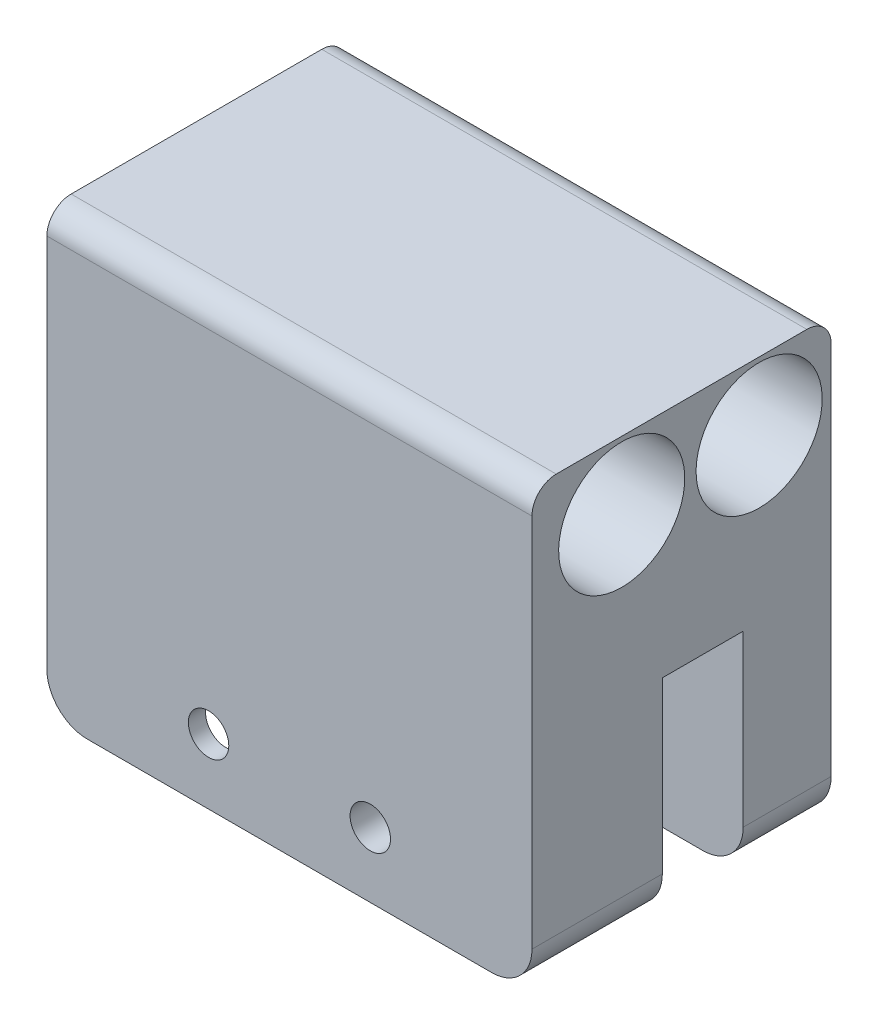
from build123d import *

# Parameters (mm, degrees)
RESSALTO_EXTRUS_O1_DEPTH = 40
ESBO_O4_R                = 7.8
CORTE_EXTRUS_O1_DEPTH    = 61
CORTE_EXTRUS_O2_DEPTH    = 3
FILETE2_R                = 3
CORTE_EXTRUS_O5_DEPTH    = 61
ESBO_O10_R               = 2.5
CORTE_EXTRUS_O6_DEPTH    = 38
ESBO_O11_R               = 4.25
CORTE_EXTRUS_O7_DEPTH    = 30
CORTE_EXTRUS_O8_DEPTH    = 30
ESBO_O13_W               = 2
ESBO_O13_H               = 5
RESSALTO_EXTRUS_O2_DEPTH = 5


with BuildPart() as part:
    # Esboço2 → Ressalto-extrusão1 (new body)
    with BuildSketch(Plane.XY):
        with BuildLine():
            Line((-246.218768802, 113.822486613), (-237.781231198, 113.822486613))
            Line((-237.781231198, 113.822486613), (-201.966801004, 113.822486613))
            Line((-201.966801004, 113.822486613), (-194.033198996, 113.822486613))
            Line((-194.033198996, 113.822486613), (-190, 113.822486613))
            Line((-190, 113.822486613), (-190, 138.123568891))
            Line((-190, 138.123568891), (-190, 163.212189341))
            ThreePointArc((-190, 163.212189341), (-191.464466094, 166.747723246), (-195, 168.212189341))
            Line((-195, 168.212189341), (-245, 168.212189341))
            ThreePointArc((-245, 168.212189341), (-248.535533906, 166.747723246), (-250, 163.212189341))
            Line((-250, 163.212189341), (-250, 138.123568891))
            Line((-250, 138.123568891), (-250, 113.822486613))
            Line((-250, 113.822486613), (-246.218768802, 113.822486613))
        make_face()
    extrude(amount=RESSALTO_EXTRUS_O1_DEPTH)

    # Esboço4 → Corte-extrusão1 (cut, through all)
    with BuildSketch(Plane(origin=(-190, 0, 0), x_dir=(0, 0, -1), z_dir=(1, 0, 0))):
        with Locations((-11.90241208, 122.212171493)):
            Circle(ESBO_O4_R)
        with Locations((-28.90241208, 122.212171493)):
            Circle(ESBO_O4_R)
    extrude(amount=-CORTE_EXTRUS_O1_DEPTH, mode=Mode.SUBTRACT)

    # Esboço5 → Corte-extrusão2 (cut)
    with BuildSketch(Plane(origin=(0, 0, 0), x_dir=(-1, 0, 0), z_dir=(0, 0, -1))):
        with BuildLine():
            Line((190, 163.212189341), (190, 113.822486613))
            Line((190, 113.822486613), (250, 113.822486613))
            Line((250, 113.822486613), (250, 163.212189341))
            ThreePointArc((250, 163.212189341), (248.535533906, 166.747723246), (245, 168.212189341))
            Line((245, 168.212189341), (195, 168.212189341))
            ThreePointArc((195, 168.212189341), (191.464466094, 166.747723246), (190, 163.212189341))
        make_face()
    extrude(amount=-CORTE_EXTRUS_O2_DEPTH, mode=Mode.SUBTRACT)

    # Filete2
    filete2_edges = [part.edges().sort_by_distance(p)[0] for p in [
        (-220, 113.822486613, 40),
        (-220, 113.822486613, 3),
    ]]
    fillet(filete2_edges, radius=FILETE2_R)

    # Esboço8 → Corte-extrusão5 (cut, through all)
    with BuildSketch(Plane.ZY.offset(250)):
        Polygon((23.874860756, 142.212171493), (23.874860756, 152.212171493), (23.874860756, 182.191519565), (13.874860756, 182.191519565), (13.874860756, 152.212171493), (13.874860756, 142.212171493), align=None)
    extrude(amount=-CORTE_EXTRUS_O5_DEPTH, mode=Mode.SUBTRACT)

    # Esboço10 → Corte-extrusão6 (cut, through all)
    with BuildSketch(Plane.XY.offset(40)):
        with Locations((-210, 160.173107934)):
            Circle(ESBO_O10_R)
        with Locations((-230, 160.173107934)):
            Circle(ESBO_O10_R)
    extrude(amount=-CORTE_EXTRUS_O6_DEPTH, mode=Mode.SUBTRACT)

    # Esboço11 → Corte-extrusão7 (cut)
    with BuildSketch(Plane(origin=(0, 168.212189341, 0), x_dir=(1, 0, 0), z_dir=(0, 1, 0))):
        with Locations((-199.5, -8.5)):
            Circle(ESBO_O11_R)
        with Locations((-240.5, -8.5)):
            Circle(ESBO_O11_R)
    extrude(amount=-CORTE_EXTRUS_O7_DEPTH, mode=Mode.SUBTRACT)

    # Esboço12 → Corte-extrusão8 (cut)
    with BuildSketch(Plane.ZY.offset(250)):
        Polygon((27.874860756, 152.212171493), (27.874860756, 142.212171493), (37.874860756, 142.212171493), (37.874860756, 152.212171493), (37.874860756, 170.639409053), (27.874860756, 170.639409053), align=None)
    extrude(amount=-CORTE_EXTRUS_O8_DEPTH, mode=Mode.SUBTRACT)


with BuildPart() as body_2:
    # Espelhar1: mirrored copy
    add(part.part.mirror(Plane(origin=(-245, 168.212189341, 40), x_dir=(0, 0, 1), z_dir=(0, -1, 0))))

    # Esboço13 → Ressalto-extrusão2 (add)
    with BuildSketch(Plane.ZY.offset(250)):
        with Locations((16.72, 203.212207189)):
            Rectangle(ESBO_O13_W, ESBO_O13_H)
    extrude(amount=RESSALTO_EXTRUS_O2_DEPTH)


solid = body_2.part
